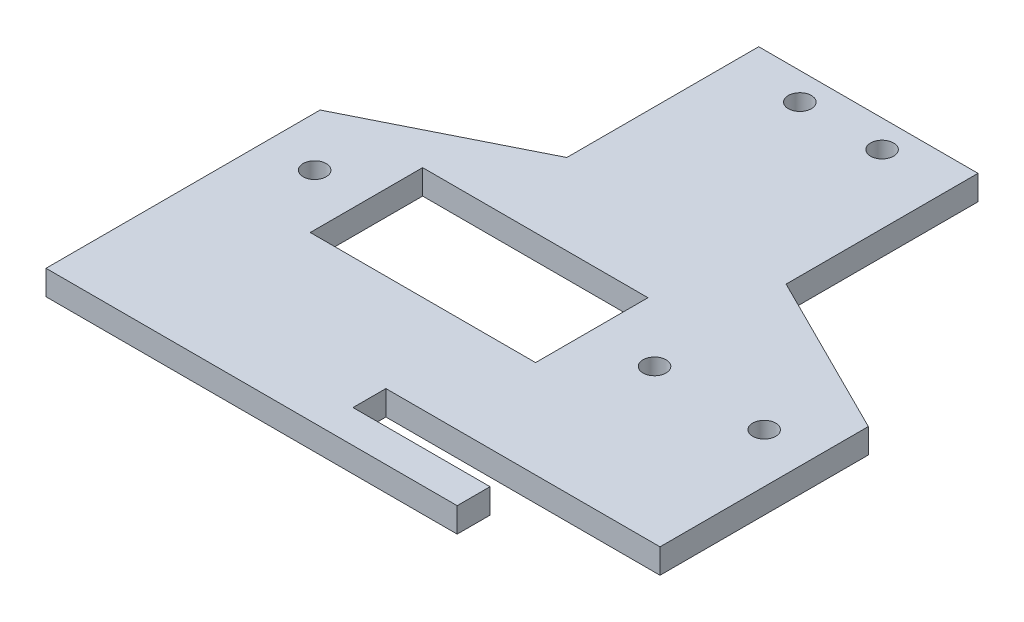
from build123d import *

# Parameters (mm, degrees)
SKETCH1_R           = 2.1
BOSS_EXTRUDE1_DEPTH = 4.5
SKETCH2_W           = 41.1
SKETCH2_H           = 20.5
CUT_EXTRUDE1_DEPTH  = 10
CUT_EXTRUDE2_DEPTH  = 10
SKETCH4_R           = 2.1
CUT_EXTRUDE3_DEPTH  = 10


with BuildPart() as part:
    # Sketch1 → Boss-Extrude1 (new body)
    with BuildSketch(Plane(origin=(0, 0, 0), x_dir=(1, 0, 0), z_dir=(0, 1, 0))):
        Polygon((20, 40), (50, 25), (50, -25), (-50, -25), (-50, 25), (-20, 40), (-20, 75), (20, 75), align=None)
        with Locations((-41, 15)):
            Circle(SKETCH1_R, mode=Mode.SUBTRACT)
        with Locations((41, 15)):
            Circle(SKETCH1_R, mode=Mode.SUBTRACT)
        with Locations((-21, 15)):
            Circle(SKETCH1_R, mode=Mode.SUBTRACT)
        with Locations((21, 15)):
            Circle(SKETCH1_R, mode=Mode.SUBTRACT)
    extrude(amount=BOSS_EXTRUDE1_DEPTH)

    # Sketch2 → Cut-Extrude1 (cut)
    with BuildSketch(Plane.XZ):
        with Locations((-11, -15)):
            Rectangle(SKETCH2_W, SKETCH2_H)
    extrude(amount=-CUT_EXTRUDE1_DEPTH, mode=Mode.SUBTRACT)

    # Sketch3 → Cut-Extrude2 (cut)
    with BuildSketch(Plane.XZ):
        Polygon((0, 19), (25, 19), (25, 28.725277581), (50, 28.725277581), (50, 19), (50, 13), (0, 13), align=None)
    extrude(amount=-CUT_EXTRUDE2_DEPTH, mode=Mode.SUBTRACT)

    # Sketch4 → Cut-Extrude3 (cut)
    with BuildSketch(Plane(origin=(0, 4.5, 0), x_dir=(1, 0, 0), z_dir=(0, 1, 0))):
        with Locations((7.5, 70)):
            Circle(SKETCH4_R)
        with Locations((-7.5, 70)):
            Circle(SKETCH4_R)
    extrude(amount=-CUT_EXTRUDE3_DEPTH, mode=Mode.SUBTRACT)


solid = part.part
